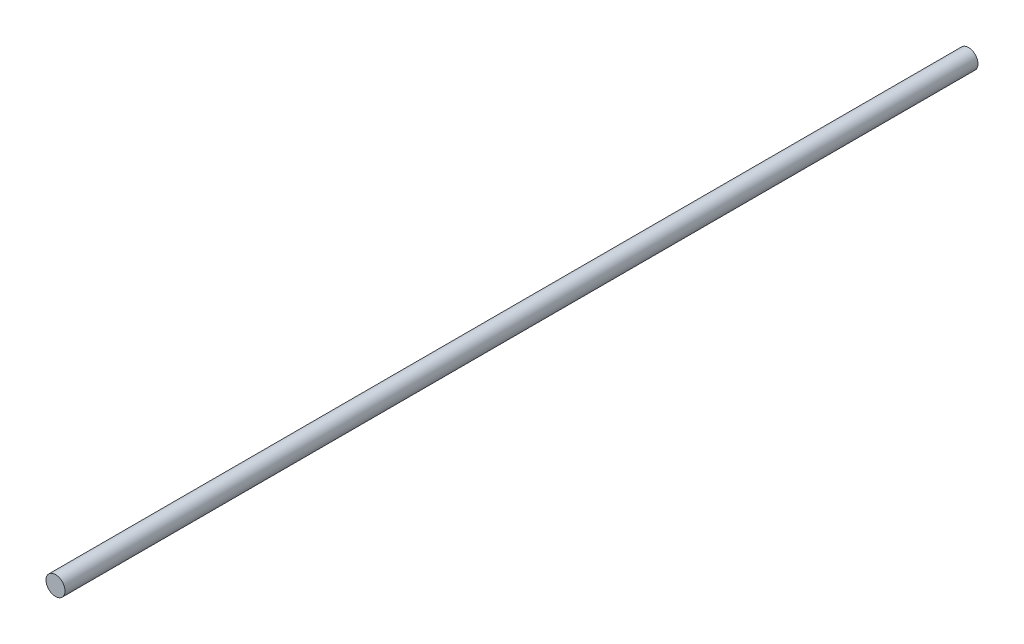
from build123d import *

# Parameters (mm, degrees)
SKETCH1_R      = 3.175
EXTRUDE1_DEPTH = 152.4


with BuildPart() as part:
    # Sketch1 → Extrude1 (new body, symmetric)
    with BuildSketch(Plane.XY):
        Circle(SKETCH1_R)
    extrude(amount=EXTRUDE1_DEPTH, both=True)


solid = part.part
